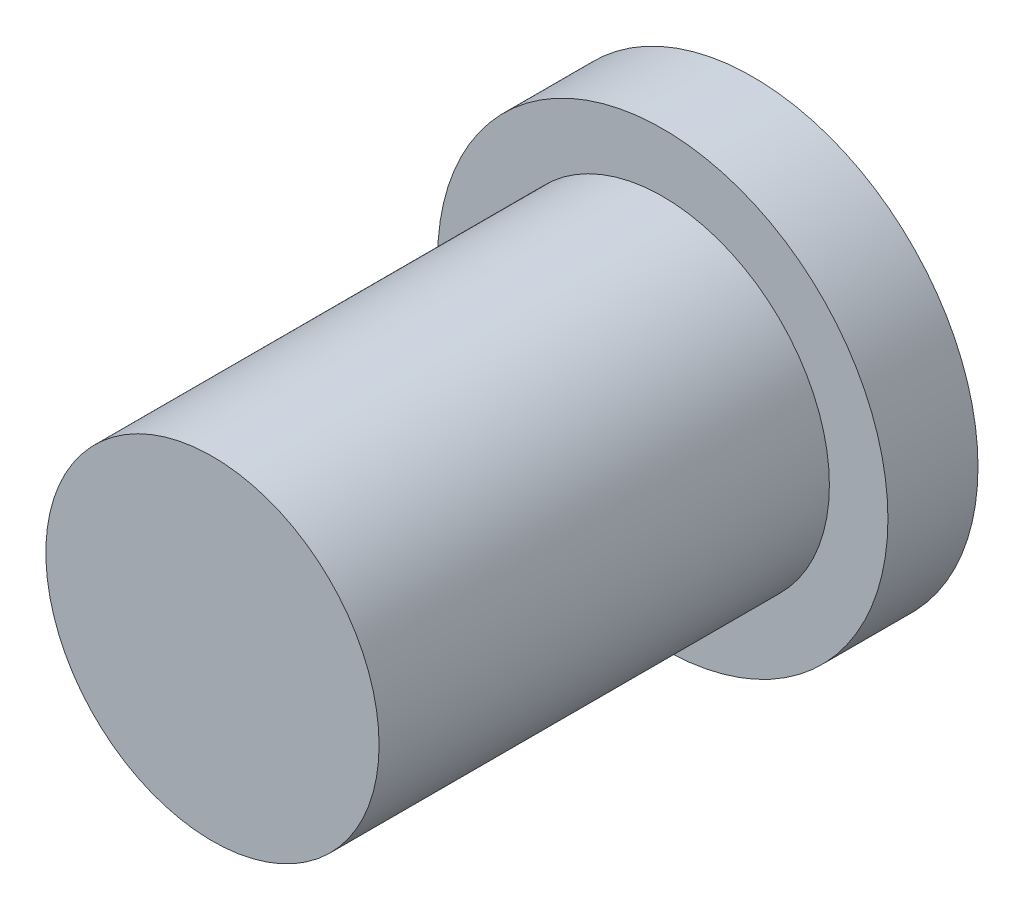
from build123d import *

# Parameters (mm, degrees)
SKETCH1_R           = 3.7
BOSS_EXTRUDE1_DEPTH = 10
SKETCH2_R           = 5
BOSS_EXTRUDE2_DEPTH = 2


with BuildPart() as part:
    # Sketch1 → Boss-Extrude1 (new body)
    with BuildSketch(Plane.XY):
        Circle(SKETCH1_R)
    extrude(amount=BOSS_EXTRUDE1_DEPTH)

    # Sketch2 → Boss-Extrude2 (add)
    with BuildSketch(Plane(origin=(0, 0, 0), x_dir=(-1, 0, 0), z_dir=(0, 0, -1))):
        Circle(SKETCH2_R)
    extrude(amount=BOSS_EXTRUDE2_DEPTH)


solid = part.part
